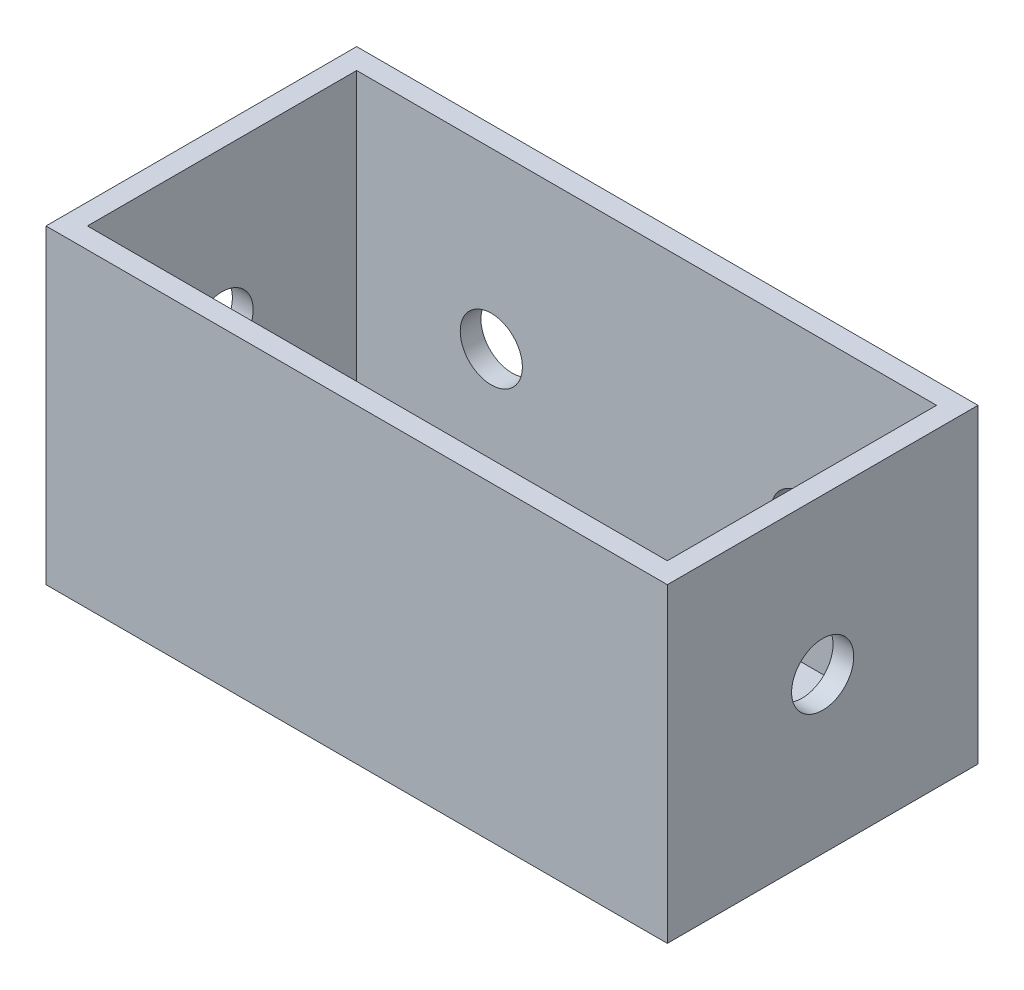
from build123d import *

# Parameters (mm, degrees)
SKETCH1_W           = 30
SKETCH1_H           = 15
BOSS_EXTRUDE1_DEPTH = 15
SKETCH2_W           = 28
SKETCH2_H           = 13
CUT_EXTRUDE1_DEPTH  = 14
SKETCH3_R           = 1.5
CUT_EXTRUDE2_DEPTH  = 31
SKETCH4_R           = 1.5
CUT_EXTRUDE3_DEPTH  = 1


with BuildPart() as part:
    # Sketch1 → Boss-Extrude1 (new body)
    with BuildSketch(Plane(origin=(0, 0, 0), x_dir=(1, 0, 0), z_dir=(0, 1, 0))):
        Rectangle(SKETCH1_W, SKETCH1_H)
    extrude(amount=BOSS_EXTRUDE1_DEPTH)

    # Sketch2 → Cut-Extrude1 (cut)
    with BuildSketch(Plane(origin=(0, 15, 0), x_dir=(1, 0, 0), z_dir=(0, 1, 0))):
        Rectangle(SKETCH2_W, SKETCH2_H)
    extrude(amount=-CUT_EXTRUDE1_DEPTH, mode=Mode.SUBTRACT)

    # Sketch3 → Cut-Extrude2 (cut, through all)
    with BuildSketch(Plane(origin=(15, 0, 0), x_dir=(0, 0, -1), z_dir=(1, 0, 0))):
        with Locations((0, 7.5)):
            Circle(SKETCH3_R)
    extrude(amount=-CUT_EXTRUDE2_DEPTH, mode=Mode.SUBTRACT)

    # Sketch4 → Cut-Extrude3 (cut)
    with BuildSketch(Plane(origin=(0, 0, -7.5), x_dir=(-1, 0, 0), z_dir=(0, 0, -1))):
        with Locations((-7.5, 6.601224847)):
            Circle(SKETCH4_R)
        with Locations((7.5, 6.601224847)):
            Circle(SKETCH4_R)
    extrude(amount=-CUT_EXTRUDE3_DEPTH, mode=Mode.SUBTRACT)


solid = part.part
